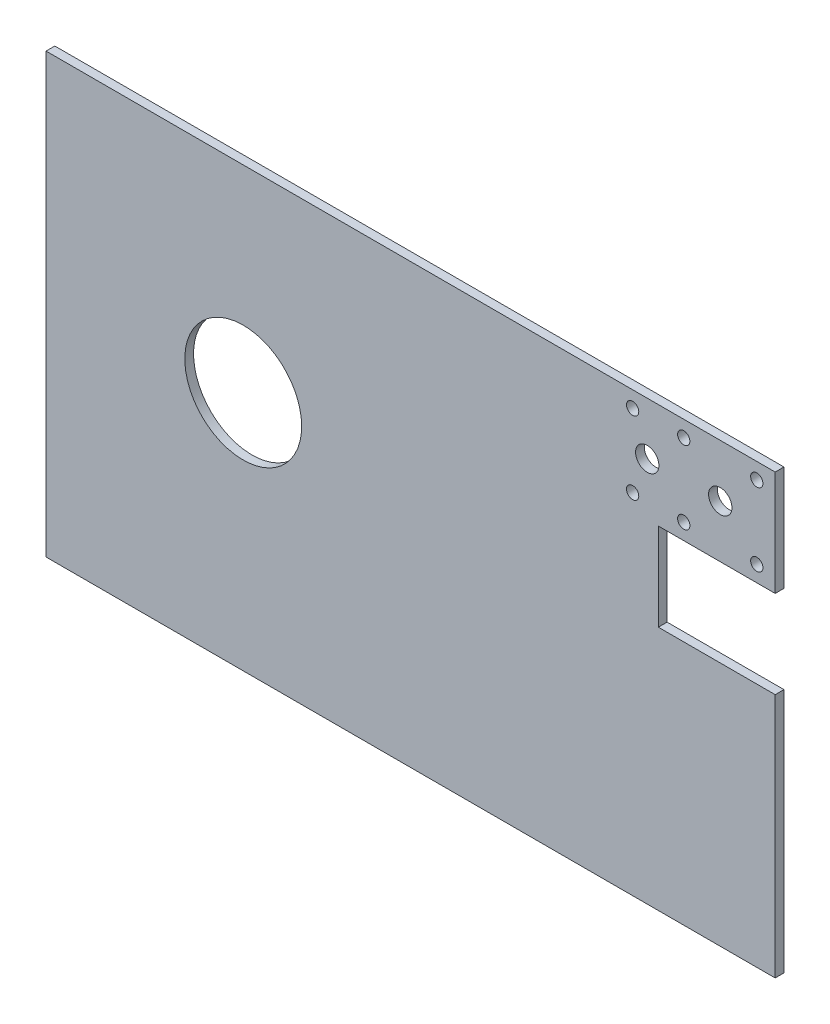
from build123d import *

# Parameters (mm, degrees)
SKETCH1_W           = 249.6
SKETCH1_H           = 150
BOSS_EXTRUDE1_DEPTH = 3
SKETCH2_R           = 20
CUT_EXTRUDE1_DEPTH  = 4
SKETCH3_W           = 40
SKETCH3_H           = 30
CUT_EXTRUDE2_DEPTH  = 5
SKETCH4_R           = 2.1
SKETCH4_R_2         = 4
CUT_EXTRUDE3_DEPTH  = 4


with BuildPart() as part:
    # Sketch1 → Boss-Extrude1 (new body)
    with BuildSketch(Plane.XY):
        with Locations((124.8, -75)):
            Rectangle(SKETCH1_W, SKETCH1_H)
    extrude(amount=BOSS_EXTRUDE1_DEPTH)

    # Sketch2 → Cut-Extrude1 (cut, through all)
    with BuildSketch(Plane.XY.offset(3)):
        with Locations((67.5, -67.5)):
            Circle(SKETCH2_R)
    extrude(amount=-CUT_EXTRUDE1_DEPTH, mode=Mode.SUBTRACT)

    # Sketch3 → Cut-Extrude2 (cut)
    with BuildSketch(Plane.XY.offset(3)):
        with Locations((229.6, -51)):
            Rectangle(SKETCH3_W, SKETCH3_H)
    extrude(amount=-CUT_EXTRUDE2_DEPTH, mode=Mode.SUBTRACT)

    # Sketch4 → Cut-Extrude3 (cut, through all)
    with BuildSketch(Plane.XY.offset(3)):
        with Locations((200.8, -5.5)):
            Circle(SKETCH4_R)
        with Locations((218.3, -5.5)):
            Circle(SKETCH4_R)
        with Locations((205.8, -18)):
            Circle(SKETCH4_R_2)
        with Locations((200.8, -30.5)):
            Circle(SKETCH4_R)
        with Locations((218.3, -30.5)):
            Circle(SKETCH4_R)
        with Locations((243.3, -5.5)):
            Circle(SKETCH4_R)
        with Locations((243.3, -30.5)):
            Circle(SKETCH4_R)
        with Locations((230.8, -18)):
            Circle(SKETCH4_R_2)
    extrude(amount=-CUT_EXTRUDE3_DEPTH, mode=Mode.SUBTRACT)


solid = part.part
